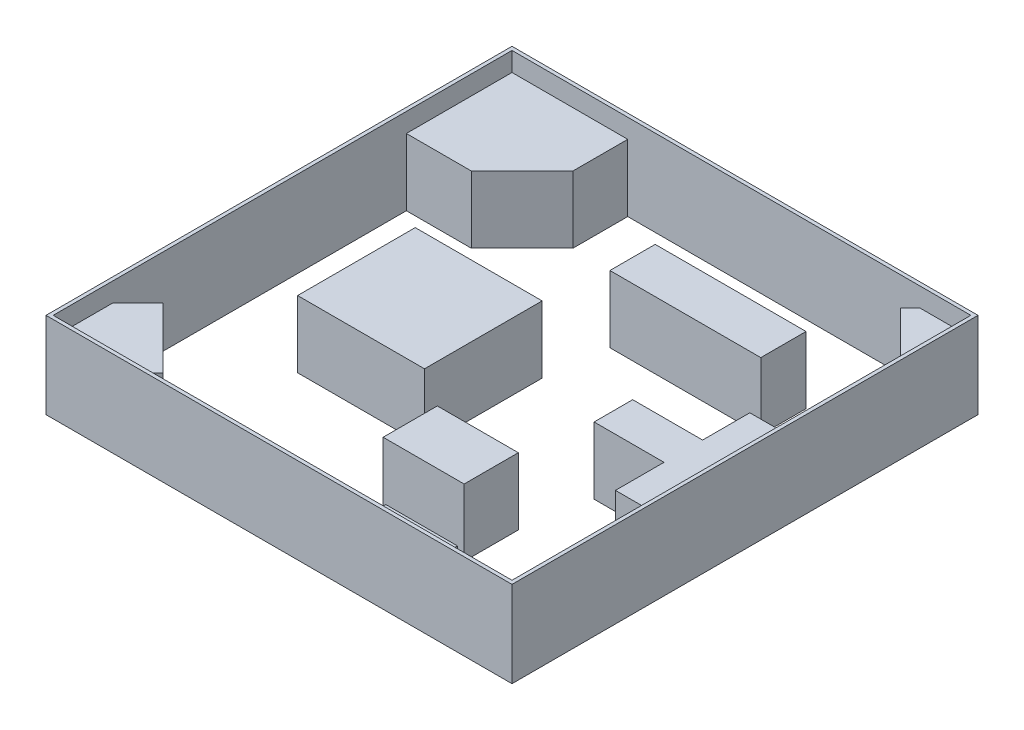
from build123d import *

# Parameters (mm, degrees)
SKETCH1_W           = 4953
SKETCH1_H           = 4953
SKETCH1_W_2         = 4876.8
SKETCH1_H_2         = 4876.8
BOSS_EXTRUDE1_DEPTH = 914.4
SKETCH3_W           = 1603.657967537
SKETCH3_H           = 481.097390261
SKETCH3_W_2         = 1348.887721916
SKETCH3_H_2         = 1250.471021175
SKETCH3_W_3         = 860.88354889
SKETCH3_H_3         = 575.861292838
SKETCH3_W_4         = 762.297956926
SKETCH3_H_4         = 229.329668114
BOSS_EXTRUDE2_DEPTH = 711.2


with BuildPart() as part:
    # Sketch1 → Boss-Extrude1 (new body)
    with BuildSketch(Plane(origin=(0, 0, 0), x_dir=(1, 0, 0), z_dir=(0, 1, 0))):
        Rectangle(SKETCH1_W, SKETCH1_H)
        Rectangle(SKETCH1_W_2, SKETCH1_H_2, mode=Mode.SUBTRACT)
    extrude(amount=BOSS_EXTRUDE1_DEPTH)

    # Sketch3 → Boss-Extrude2 (add)
    with BuildSketch(Plane(origin=(0, 0, 0), x_dir=(1, 0, 0), z_dir=(0, 1, 0))):
        Polygon((-1208.166340479, 2438.4), (-1208.166340479, 1859.100828323), (-1747.914241925, 1315.794340557), (-2438.4, 1315.794340557), (-2438.4, 2438.4), align=None)
        Polygon((1900.060182517, 2438.4), (1796.390856931, 2334.730674414), (2316.973334208, 1814.148197136), (2438.4, 1935.574862928), (2438.4, 2438.4), align=None)
        with Locations((706.202427143, 1376.817191918)):
            Rectangle(SKETCH3_W, SKETCH3_H)
        with Locations((-850.522821308, -128.750138427)):
            Rectangle(SKETCH3_W_2, SKETCH3_H_2)
        with Locations((664.479751449, -1315.769786399)):
            Rectangle(SKETCH3_W_3, SKETCH3_H_3)
        Polygon((2438.4, 569.939941463), (1957.659619596, 569.939941463), (1957.659619596, 68.174197664), (1214.660345125, 68.174197664), (1214.660345125, -341.92280448), (1957.659619596, -341.92280448), (1957.659619596, -858.162560119), (2438.4, -858.162560119), align=None)
        with Locations((1248.433039419, -2323.735165943)):
            Rectangle(SKETCH3_W_4, SKETCH3_H_4)
        Polygon((-1781.46010583, -2438.4), (-1524.966682266, -2181.906576436), (-2170.345283803, -1536.527974899), (-2438.4, -1804.582691096), (-2438.4, -2438.4), align=None)
    extrude(amount=BOSS_EXTRUDE2_DEPTH)


solid = part.part
